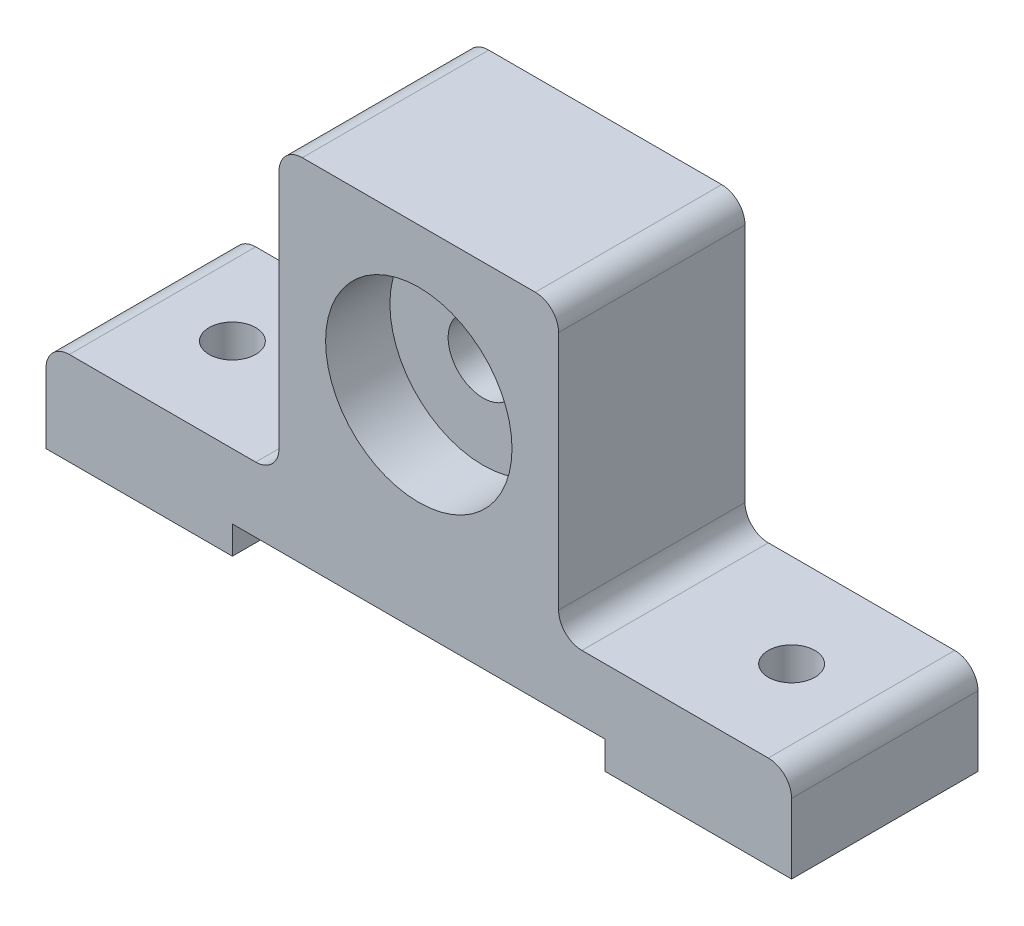
from build123d import *

# Parameters (mm, degrees)
BOSS_EXTRUDE1_DEPTH = 50.8
SKETCH6_R           = 9.525
CUT_EXTRUDE1_DEPTH  = 50.8
SKETCH7_R           = 25.4
CUT_EXTRUDE2_DEPTH  = 17.526
SKETCH8_R           = 6.35
CUT_EXTRUDE3_DEPTH  = 26.4
SKETCH9_R           = 6.35
CUT_EXTRUDE4_DEPTH  = 26.4


with BuildPart() as part:
    # Sketch5 → Boss-Extrude1 (new body)
    with BuildSketch(Plane.XY):
        with BuildLine():
            Line((6.35, 25.4), (57.15, 25.4))
            ThreePointArc((57.15, 25.4), (61.640128061, 27.259871939), (63.5, 31.75))
            Line((63.5, 31.75), (63.5, 97.24338288))
            ThreePointArc((63.5, 97.24338288), (65.359871939, 101.73351094), (69.85, 103.59338288))
            Line((69.85, 103.59338288), (133.35, 103.59338288))
            ThreePointArc((133.35, 103.59338288), (137.840128061, 101.73351094), (139.7, 97.24338288))
            Line((139.7, 97.24338288), (139.7, 31.75))
            ThreePointArc((139.7, 31.75), (141.559871939, 27.259871939), (146.05, 25.4))
            Line((146.05, 25.4), (196.85, 25.4))
            ThreePointArc((196.85, 25.4), (201.340128061, 23.540128061), (203.2, 19.05))
            Line((203.2, 19.05), (203.2, 0))
            Line((203.2, 0), (152.4, 0))
            Line((152.4, 0), (152.4, 7.62))
            Line((152.4, 7.62), (50.8, 7.62))
            Line((50.8, 7.62), (50.8, 0))
            Line((50.8, 0), (0, 0))
            Line((0, 0), (0, 19.05))
            ThreePointArc((0, 19.05), (1.859871939, 23.540128061), (6.35, 25.4))
        make_face()
    extrude(amount=-BOSS_EXTRUDE1_DEPTH)

    # Sketch6 → Cut-Extrude1 (cut)
    with BuildSketch(Plane.XY):
        with Locations((101.6, 63.5)):
            Circle(SKETCH6_R)
    extrude(amount=-CUT_EXTRUDE1_DEPTH, mode=Mode.SUBTRACT)

    # Sketch7 → Cut-Extrude2 (cut)
    with BuildSketch(Plane.XY):
        with Locations((101.6, 63.5)):
            Circle(SKETCH7_R)
    extrude(amount=-CUT_EXTRUDE2_DEPTH, mode=Mode.SUBTRACT)

    # Sketch8 → Cut-Extrude3 (cut, through all)
    with BuildSketch(Plane(origin=(0, 25.4, 0), x_dir=(1, 0, 0), z_dir=(0, 1, 0))):
        with Locations((25.4, 25.4)):
            Circle(SKETCH8_R)
    extrude(amount=-CUT_EXTRUDE3_DEPTH, mode=Mode.SUBTRACT)

    # Sketch9 → Cut-Extrude4 (cut, through all)
    with BuildSketch(Plane(origin=(0, 25.4, 0), x_dir=(1, 0, 0), z_dir=(0, 1, 0))):
        with Locations((177.8, 25.4)):
            Circle(SKETCH9_R)
    extrude(amount=-CUT_EXTRUDE4_DEPTH, mode=Mode.SUBTRACT)


solid = part.part
